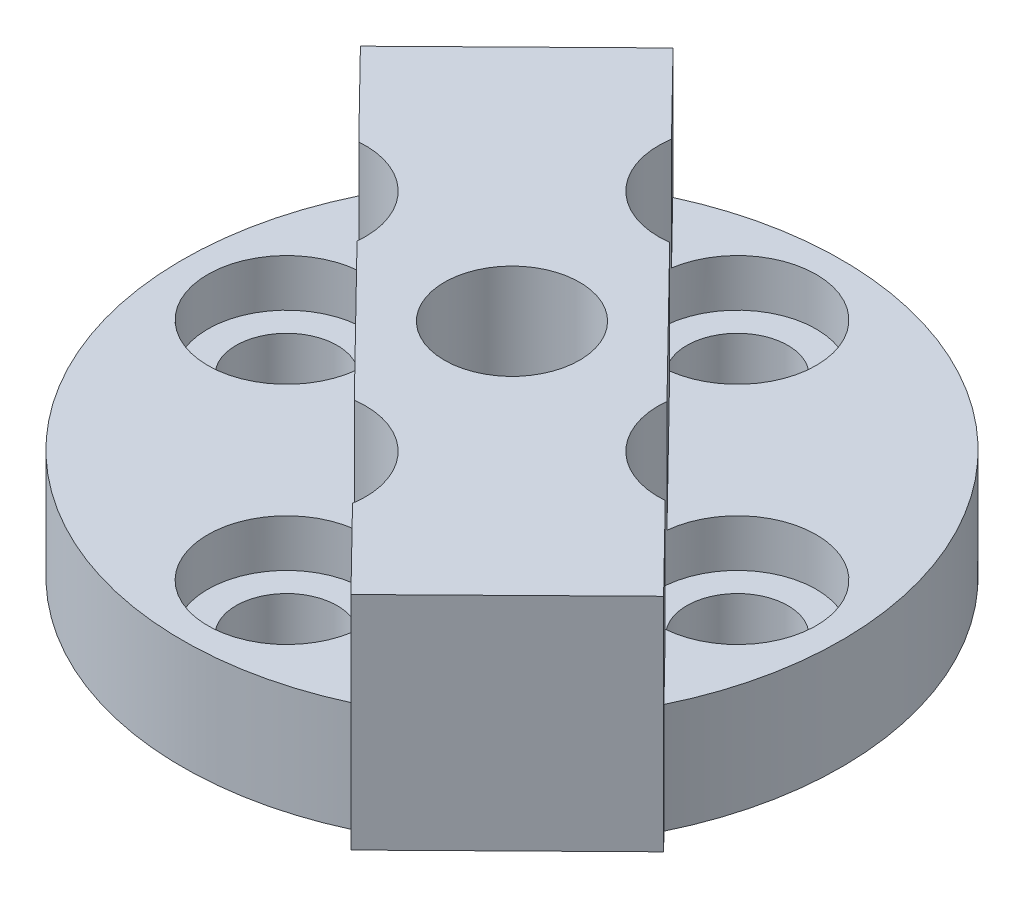
from build123d import *

# Parameters (mm, degrees)
SKETCH1_R           = 18.57375
SKETCH1_R_2         = 2.85115
BOSS_EXTRUDE1_DEPTH = 6.1849
BOSS_EXTRUDE2_DEPTH = 12.4714
SKETCH3_R           = 4.445
CUT_EXTRUDE1_DEPTH  = 2.667
CIRPATTERN1_COUNT   = 4
SKETCH4_R           = 3.81
CUT_EXTRUDE2_DEPTH  = 5.715
SKETCH5_R           = 3.175
CUT_EXTRUDE3_DEPTH  = 7.7564


with BuildPart() as part:
    # Sketch1 → Boss-Extrude1 (new body)
    with BuildSketch(Plane(origin=(0, 0, 0), x_dir=(1, 0, 0), z_dir=(0, 1, 0))):
        Circle(SKETCH1_R)
        with Locations((0, 12.7)):
            Circle(SKETCH1_R_2, mode=Mode.SUBTRACT)
        with Locations((-12.7, 0)):
            Circle(SKETCH1_R_2, mode=Mode.SUBTRACT)
        with Locations((0, -12.7)):
            Circle(SKETCH1_R_2, mode=Mode.SUBTRACT)
        with Locations((12.7, 0)):
            Circle(SKETCH1_R_2, mode=Mode.SUBTRACT)
    extrude(amount=BOSS_EXTRUDE1_DEPTH)

    # Sketch2 → Boss-Extrude2 (add)
    with BuildSketch(Plane(origin=(0, 0, 0), x_dir=(1, 0, 0), z_dir=(0, 1, 0))):
        with BuildLine():
            Line((-8.797939445, 17.874031217), (-4.392677204, 13.380008809))
            ThreePointArc((-4.392677204, 13.380008809), (-3.174280479, 9.588413838), (0.592258402, 8.294633388))
            Line((0.592258402, 8.294633388), (8.278225813, 0.453803969))
            ThreePointArc((8.278225813, 0.453803969), (9.525719521, -3.111586162), (13.065518202, -4.429945987))
            Line((13.065518202, -4.429945987), (17.694994159, -9.152699719))
            Line((17.694994159, -9.152699719), (8.797939445, -17.874031217))
            Line((8.797939445, -17.874031217), (4.392677204, -13.380008809))
            ThreePointArc((4.392677204, -13.380008809), (3.174280479, -9.588413838), (-0.592258402, -8.294633388))
            Line((-0.592258402, -8.294633388), (-8.278225813, -0.453803969))
            ThreePointArc((-8.278225813, -0.453803969), (-9.525719521, 3.111586162), (-13.065518202, 4.429945987))
            Line((-13.065518202, 4.429945987), (-17.694994159, 9.152699719))
            Line((-17.694994159, 9.152699719), (-8.797939445, 17.874031217))
        make_face()
    extrude(amount=BOSS_EXTRUDE2_DEPTH)

    # Sketch3 → Cut-Extrude1 (cut)
    with BuildSketch(Plane(origin=(0, 6.1849, 0), x_dir=(1, 0, 0), z_dir=(0, 1, 0))):
        with Locations((0, -12.7)):
            Circle(SKETCH3_R)
    cut_extrude1 = extrude(amount=-CUT_EXTRUDE1_DEPTH, mode=Mode.SUBTRACT)

    # CirPattern1: Cut-Extrude1 ×4 about axis
    cirpattern1_axis = Axis((0, 6.1849, 0), (0, -1, 0))
    for i in range(1, CIRPATTERN1_COUNT):
        add(cut_extrude1.rotate(cirpattern1_axis, i * 360 / CIRPATTERN1_COUNT), mode=Mode.SUBTRACT)

    # Sketch4 → Cut-Extrude2 (cut)
    with BuildSketch(Plane(origin=(0, 12.4714, 0), x_dir=(1, 0, 0), z_dir=(0, 1, 0))):
        Circle(SKETCH4_R)
    extrude(amount=-CUT_EXTRUDE2_DEPTH, mode=Mode.SUBTRACT)

    # Sketch5 → Cut-Extrude3 (cut, through all)
    with BuildSketch(Plane(origin=(0, 6.7564, 0), x_dir=(1, 0, 0), z_dir=(0, 1, 0))):
        Circle(SKETCH5_R)
    extrude(amount=-CUT_EXTRUDE3_DEPTH, mode=Mode.SUBTRACT)


solid = part.part
